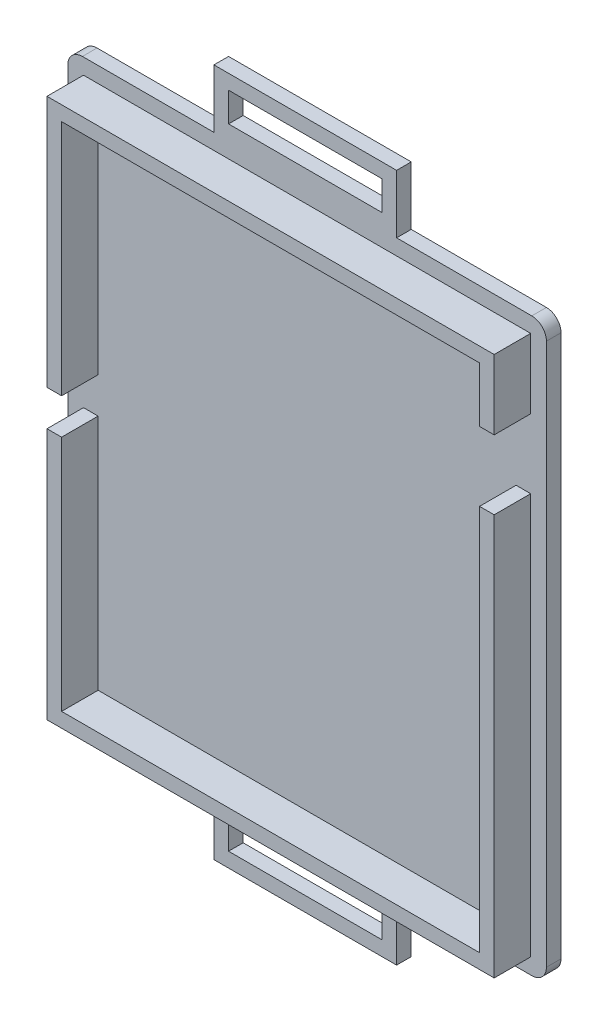
from build123d import *

# Parameters (mm, degrees)
SKETCH1_W           = 65.5
SKETCH1_H           = 78.2
BOSS_EXTRUDE1_DEPTH = 2
SKETCH2_W           = 61.2
SKETCH2_H           = 73.9
SKETCH2_W_2         = 57.2
SKETCH2_H_2         = 69.9
BOSS_EXTRUDE2_DEPTH = 5
SKETCH3_W           = 5
SKETCH3_H           = 9.47
CUT_EXTRUDE1_DEPTH  = 2
SKETCH4_W           = 5
SKETCH4_H           = 4.9
CUT_EXTRUDE2_DEPTH  = 2
FILLET1_R           = 2
SKETCH5_W           = 25
SKETCH5_H           = 2
BOSS_EXTRUDE3_DEPTH = 8
SKETCH6_W           = 25
SKETCH6_H           = 2
BOSS_EXTRUDE4_DEPTH = 8
SKETCH7_W           = 21
SKETCH7_H           = 4
CUT_EXTRUDE3_DEPTH  = 3


with BuildPart() as part:
    # Sketch1 → Boss-Extrude1 (new body)
    with BuildSketch(Plane.XY):
        with Locations((4.011517615, -7.43604336)):
            Rectangle(SKETCH1_W, SKETCH1_H)
    extrude(amount=BOSS_EXTRUDE1_DEPTH)

    # Sketch2 → Boss-Extrude2 (add)
    with BuildSketch(Plane.XY.offset(2)):
        with Locations((4.011517615, -7.43604336)):
            Rectangle(SKETCH2_W, SKETCH2_H)
        with Locations((4.011517615, -7.43604336)):
            Rectangle(SKETCH2_W_2, SKETCH2_H_2, mode=Mode.SUBTRACT)
    extrude(amount=BOSS_EXTRUDE2_DEPTH)

    # Sketch3 → Cut-Extrude1 (cut)
    with BuildSketch(Plane(origin=(34.611517615, 0, 0), x_dir=(0, 0, -1), z_dir=(1, 0, 0))):
        with Locations((-4.5, 15.24895664)):
            Rectangle(SKETCH3_W, SKETCH3_H)
    extrude(amount=-CUT_EXTRUDE1_DEPTH, mode=Mode.SUBTRACT)

    # Sketch4 → Cut-Extrude2 (cut)
    with BuildSketch(Plane.ZY.offset(26.588482385)):
        with Locations((4.5, -7.43604336)):
            Rectangle(SKETCH4_W, SKETCH4_H)
    extrude(amount=-CUT_EXTRUDE2_DEPTH, mode=Mode.SUBTRACT)

    # Fillet1
    fillet1_edges = [part.edges().sort_by_distance(p)[0] for p in [
        (-28.738482385, 31.66395664, 1),
        (36.761517615, 31.66395664, 1),
        (36.761517615, -46.53604336, 1),
        (-28.738482385, -46.53604336, 1),
    ]]
    fillet(fillet1_edges, radius=FILLET1_R)

    # Sketch5 → Boss-Extrude3 (add)
    with BuildSketch(Plane(origin=(0, 31.66395664, 0), x_dir=(1, 0, 0), z_dir=(0, 1, 0))):
        with Locations((3.761517615, -1)):
            Rectangle(SKETCH5_W, SKETCH5_H)
    extrude(amount=BOSS_EXTRUDE3_DEPTH)

    # Sketch6 → Boss-Extrude4 (add)
    with BuildSketch(Plane.XZ.offset(46.53604336)):
        with Locations((3.761517615, 1)):
            Rectangle(SKETCH6_W, SKETCH6_H)
    extrude(amount=BOSS_EXTRUDE4_DEPTH)

    # Sketch7 → Cut-Extrude3 (cut, through all)
    with BuildSketch(Plane.XY.offset(2)):
        with Locations((3.761517615, -50.53604336)):
            Rectangle(SKETCH7_W, SKETCH7_H)
        with Locations((3.761517615, 35.66395664)):
            Rectangle(SKETCH7_W, SKETCH7_H)
    extrude(amount=-CUT_EXTRUDE3_DEPTH, mode=Mode.SUBTRACT)


solid = part.part
